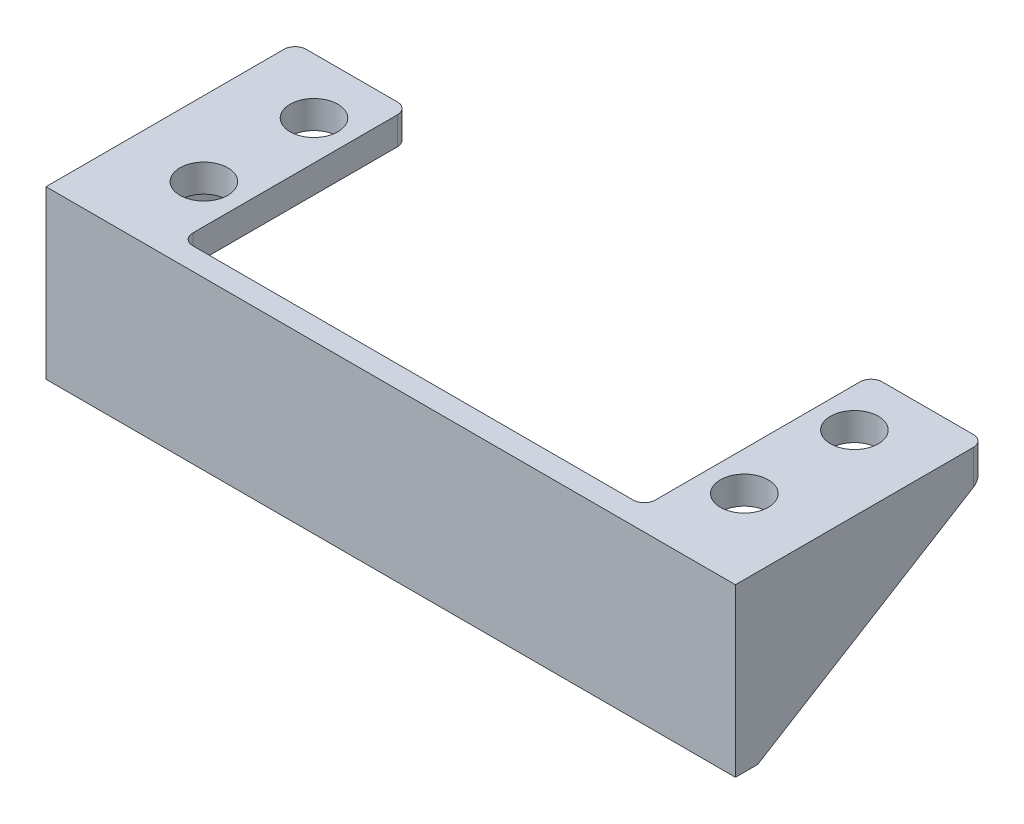
from build123d import *

# Parameters (mm, degrees)
SKETCH_1_W             = 29
SKETCH_1_H             = 15
EXTRUDE_1_DEPTH        = 2
SKETCH_2_W             = 8.2
SKETCH_2_H             = 20.4
SKETCH_2_R             = 2.15
EXTRUDE_2_DEPTH        = 2.5
EXTRUDE_3_DEPTH        = 2
FILLET_1_R             = 1
FILLET_1_OF_MIRROR_2_R = 1


with BuildPart() as part:
    # 草图1 → 凸台-拉伸1 (new body)
    with BuildSketch(Plane.XY):
        with Locations((-14.5, 7.5)):
            Rectangle(SKETCH_1_W, SKETCH_1_H)
    extrude_1 = extrude(amount=EXTRUDE_1_DEPTH)

    # 草图2 → 凸台-拉伸2 (add)
    with BuildSketch(Plane(origin=(0, 15, 0), x_dir=(1, 0, 0), z_dir=(0, 1, 0))):
        with Locations((-24.9, 10.2)):
            Rectangle(SKETCH_2_W, SKETCH_2_H)
        with Locations((-24.3, 5.5)):
            Circle(SKETCH_2_R, mode=Mode.SUBTRACT)
        with Locations((-24.3, 15.4)):
            Circle(SKETCH_2_R, mode=Mode.SUBTRACT)
    extrude_2 = extrude(amount=-EXTRUDE_2_DEPTH)

    # 草图3 → 凸台-拉伸3 (add)
    with BuildSketch(Plane.ZY.offset(29)):
        Polygon((-20.4, 12.5), (0, 0), (0, 12.5), align=None)
        Polygon((2, 0), (2, 15), (-20.4, 15), (-20.4, 12.5), (0, 12.5), (0, 0), align=None)
    extrude_3 = extrude(amount=EXTRUDE_3_DEPTH)

    # 圆角1
    fillet_1_edges = [part.edges().sort_by_distance(p)[0] for p in [
        (-29, 6.25, 0),
        (-20.8, 13.75, 0),
        (-20.8, 13.75, -20.4),
        (-24.9, 12.5, 0),
        (-29, 12.5, -10.2),
        (-31, 13.75, -20.4),
    ]]
    fillet(fillet_1_edges, radius=FILLET_1_R)

    # 镜向2: 凸台-拉伸1, 凸台-拉伸2, 凸台-拉伸3 across plane
    add(extrude_1.mirror(Plane(origin=(0, 0, 2), x_dir=(0, 0, 1), z_dir=(-1, 0, 0))))
    add(extrude_2.mirror(Plane(origin=(0, 0, 2), x_dir=(0, 0, 1), z_dir=(-1, 0, 0))))
    add(extrude_3.mirror(Plane(origin=(0, 0, 2), x_dir=(0, 0, 1), z_dir=(-1, 0, 0))))

    # 圆角1 of 镜向2
    fillet_1_of_mirror_2_edges = [part.edges().sort_by_distance(p)[0] for p in [
        (29, 6.25, 0),
        (20.8, 13.75, 0),
        (20.8, 13.75, -20.4),
        (24.9, 12.5, 0),
        (29, 12.5, -10.2),
        (31, 13.75, -20.4),
    ]]
    fillet(fillet_1_of_mirror_2_edges, radius=FILLET_1_OF_MIRROR_2_R)


solid = part.part
